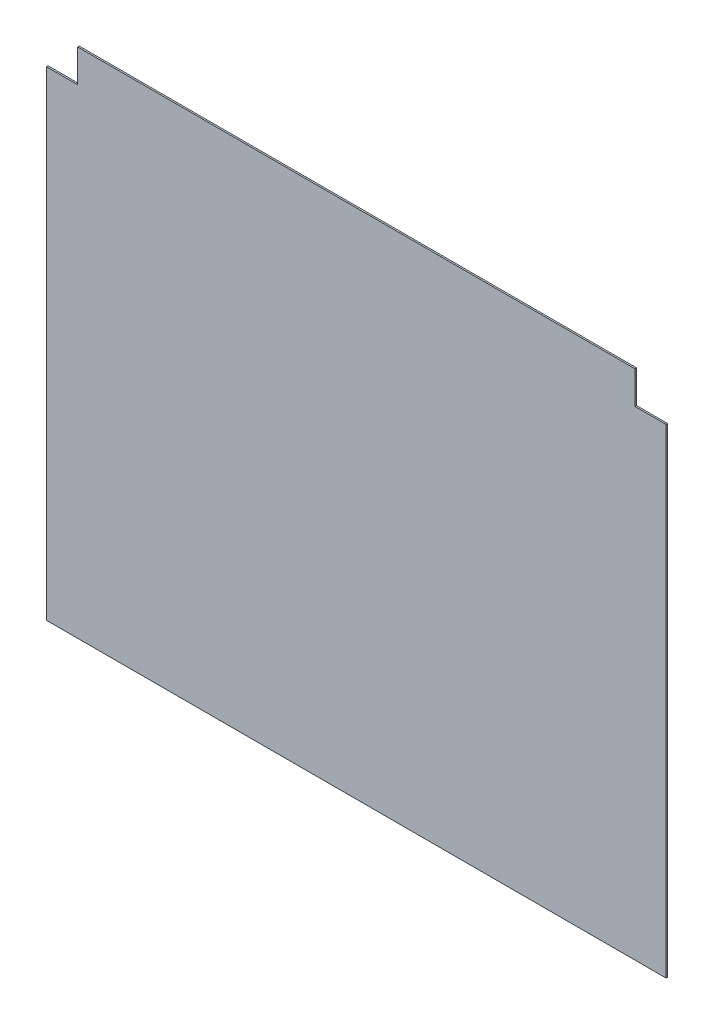
from build123d import *

# Parameters (mm, degrees)
EXTRUDE_1_DEPTH = 1


with BuildPart() as part:
    # 스케치1 → 보스-돌출1 (new body)
    with BuildSketch(Plane.XY):
        Polygon((0, 0), (398, 0), (398, 308), (378, 308), (378, 329), (20, 329), (20, 308), (0, 308), align=None)
    extrude(amount=EXTRUDE_1_DEPTH)


solid = part.part
